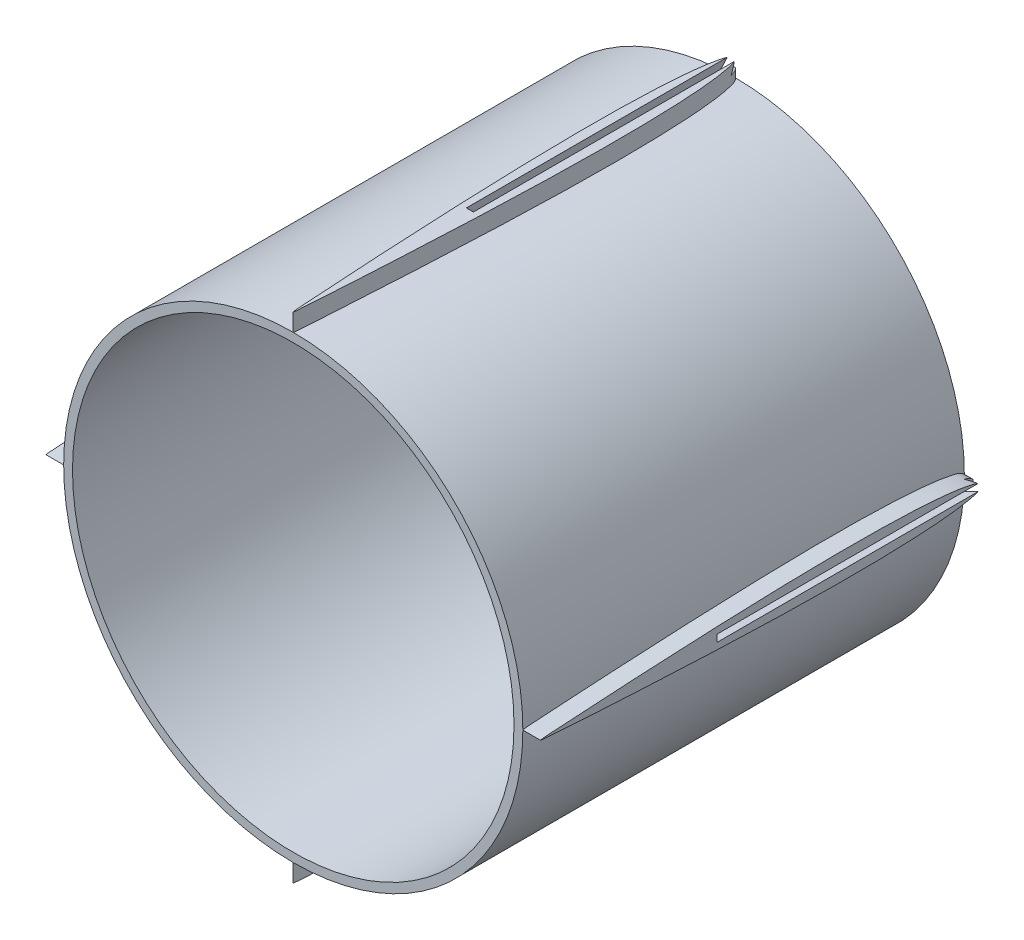
from build123d import *

# Parameters (mm, degrees)
SKETCH2_R           = 26
SKETCH2_R_2         = 25
BOSS_EXTRUDE1_DEPTH = 50
BOSS_EXTRUDE2_START = 28
BOSS_EXTRUDE2_DEPTH = 2.5
CUT_EXTRUDE1_DEPTH  = 30
CIRPATTERN1_COUNT   = 4


with BuildPart() as part:
    # Sketch2 → Boss-Extrude1 (new body)
    with BuildSketch(Plane.XY):
        Circle(SKETCH2_R)
        Circle(SKETCH2_R_2, mode=Mode.SUBTRACT)
    extrude(amount=BOSS_EXTRUDE1_DEPTH)

    # Sketch4 → Boss-Extrude2 (add)
    with BuildSketch(Plane(origin=(0, 0, 0), x_dir=(1, 0, 0), z_dir=(0, 1, 0)).offset(BOSS_EXTRUDE2_START)):
        with BuildLine():
            add(Edge.make_bspline(
                [(0, -50), (0.070574794, -50), (0.211641076, -47.125457824), (0.411982789, -44.384002629), (0.663217828, -39.927347093), (0.921106295, -35.020545166), (1.148106942, -29.995590241), (1.332253534, -25.002269837), (1.463720169, -20.000338655), (1.50961292, -15.833475854), (1.491450885, -12.499733372), (1.442100876, -9.999450324), (1.347002787, -7.497847023), (1.21482098, -5.415781084), (1.054842987, -3.745401607), (0.904008723, -2.503915111), (0.696273378, -1.421838007), (0.512523451, -0.628600997), (0, 0.343595251), (-0.512523451, -0.628600997), (-0.696273378, -1.421838007), (-0.904008723, -2.503915111), (-1.054842987, -3.745401607), (-1.21482098, -5.415781084), (-1.347002787, -7.497847023), (-1.442100876, -9.999450324), (-1.491450885, -12.499733372), (-1.50961292, -15.833475854), (-1.463720169, -20.000338655), (-1.332253534, -25.002269837), (-1.148106942, -29.995590241), (-0.921106295, -35.020545166), (-0.663217828, -39.927347093), (-0.411982789, -44.384002629), (-0.211641076, -47.125457824), (-0.070574794, -50), (0, -50)],
                knots=[0, 0, 0, 0, 0.024946615, 0.049863783, 0.099681635, 0.149480781, 0.199263062, 0.249028132, 0.298776252, 0.348510643, 0.373377067, 0.398248217, 0.423133292, 0.448054025, 0.460544649, 0.473080978, 0.485731774, 0.492200943, 0.5, 0.507799057, 0.514268226, 0.526919022, 0.539455351, 0.551945975, 0.576866708, 0.601751783, 0.626622933, 0.651489357, 0.701223748, 0.750971868, 0.800736938, 0.850519219, 0.900318365, 0.950136217, 0.975053385, 1, 1, 1, 1], degree=3))
        make_face()
    boss_extrude2 = extrude(amount=-BOSS_EXTRUDE2_DEPTH)

    # Sketch5 → Cut-Extrude1 (cut)
    with BuildSketch(Plane(origin=(0, 0, 0), x_dir=(-1, 0, 0), z_dir=(0, 0, -1))):
        Polygon((-0.4, 28), (0.4, 28), (0.6, 27), (-0.6, 27), align=None)
    cut_extrude1 = extrude(amount=-CUT_EXTRUDE1_DEPTH, mode=Mode.SUBTRACT)

    # CirPattern1: Boss-Extrude2, Cut-Extrude1 ×4 about axis
    cirpattern1_axis = Axis((0, 0, 50), (0, 0, -1))
    add([boss_extrude2.rotate(cirpattern1_axis, i * 360 / CIRPATTERN1_COUNT) for i in range(1, CIRPATTERN1_COUNT)])
    add([cut_extrude1.rotate(cirpattern1_axis, i * 360 / CIRPATTERN1_COUNT) for i in range(1, CIRPATTERN1_COUNT)], mode=Mode.SUBTRACT)


solid = part.part
